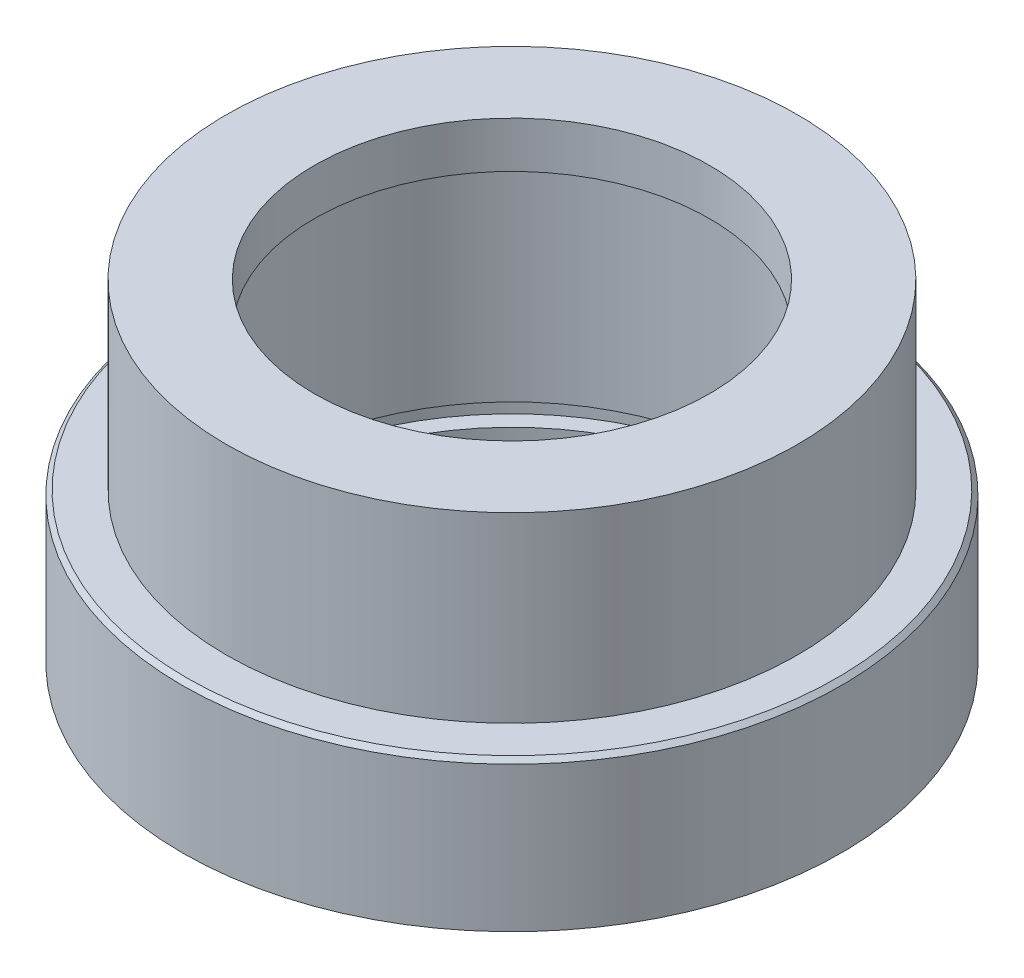
from build123d import *


with BuildPart() as part:
    # Sketch1 → Revolve1 (revolve)
    with BuildSketch(Plane.XY):
        Polygon((-9, 7.35), (-13, 7.35), (-13, -0.95), (-14.8, -0.95), (-15, -1.15), (-15, -7.75), (-11, -7.75), (-11, -6.25), (-11.75, -6.25), (-11.75, -5.25), (-11, -5.25), (-11, 5.25), (-9, 5.25), align=None)
    revolve(axis=Axis((0, 0, 0), (0, -1, 0)))


solid = part.part
